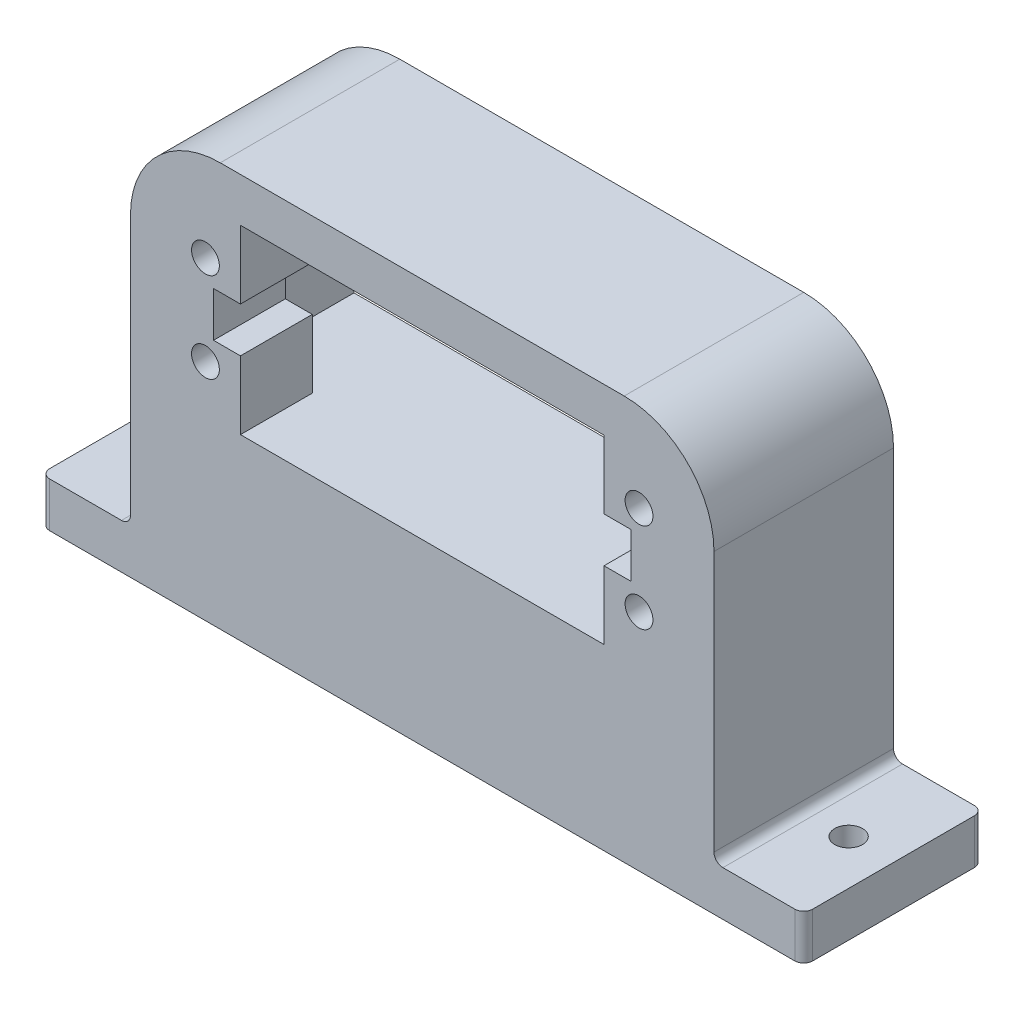
from build123d import *

# Parameters (mm, degrees)
BOSS_EXTRUDE1_DEPTH = 10
SKETCH3_R           = 1.55
CUT_EXTRUDE1_DEPTH  = 12
SKETCH3_3_R         = 1.55
CUT_EXTRUDE3_DEPTH  = 66.048059156
SKETCH5_R           = 1.55
CUT_EXTRUDE4_DEPTH  = 60.213596412
FILLET1_R           = 1


with BuildPart() as part:
    # Sketch1 → Boss-Extrude1 (new, symmetric)
    with BuildSketch(Plane.XY):
        with BuildLine():
            Line((-42.5, 0), (42.5, 0))
            Line((42.5, 0), (42.5, 5))
            Line((42.5, 5), (32.5, 5))
            Line((32.5, 5), (32.5, 35))
            ThreePointArc((32.5, 35), (29.571067812, 42.071067812), (22.5, 45))
            Line((22.5, 45), (-22.5, 45))
            ThreePointArc((-22.5, 45), (-29.571067812, 42.071067812), (-32.5, 35))
            Line((-32.5, 35), (-32.5, 5))
            Line((-32.5, 5), (-42.5, 5))
            Line((-42.5, 5), (-42.5, 0))
        make_face()
    extrude(amount=BOSS_EXTRUDE1_DEPTH, both=True)

    # Sketch3 → Cut-Extrude1 (cut)
    # profile 1 of 2: a face of its own
    with BuildSketch(Plane(origin=(0, 0, -10), x_dir=(-1, 0, 0), z_dir=(0, 0, -1))):
        Polygon((-27.6, 40.1), (-27.6, 19.9), (-20.25, 19.9), (-20.25, 27.5), (-23.25, 27.5), (-23.25, 32.5), (-20.25, 32.5), (-20.25, 40.1), align=None)
        with Locations((-24.15, 25)):
            Circle(SKETCH3_R, mode=Mode.SUBTRACT)
        with Locations((-24.15, 35)):
            Circle(SKETCH3_R, mode=Mode.SUBTRACT)
    # profile 2 of 2: a face of its own
    with BuildSketch(Plane(origin=(0, 0, -10), x_dir=(-1, 0, 0), z_dir=(0, 0, -1))):
        Polygon((20.25, 27.5), (20.25, 19.9), (27.6, 19.9), (27.6, 40.1), (20.25, 40.1), (20.25, 32.5), (23.25, 32.5), (23.25, 27.5), align=None)
        with Locations((24.15, 25)):
            Circle(SKETCH3_R, mode=Mode.SUBTRACT)
        with Locations((24.15, 35)):
            Circle(SKETCH3_R, mode=Mode.SUBTRACT)
    extrude(amount=-CUT_EXTRUDE1_DEPTH, mode=Mode.SUBTRACT)

    # Sketch3_3 → Cut-Extrude3 (cut, through all)
    with BuildSketch(Plane(origin=(0, 0, -10), x_dir=(-1, 0, 0), z_dir=(0, 0, -1))):
        Polygon((-20.25, 27.5), (-20.25, 19.9), (20.25, 19.9), (20.25, 27.5), (23.25, 27.5), (23.25, 32.5), (20.25, 32.5), (20.25, 40.1), (-20.25, 40.1), (-20.25, 32.5), (-23.25, 32.5), (-23.25, 27.5), align=None)
        with Locations((-24.15, 25)):
            Circle(SKETCH3_3_R)
        with Locations((24.15, 25)):
            Circle(SKETCH3_3_R)
        with Locations((-24.15, 35)):
            Circle(SKETCH3_3_R)
        with Locations((24.15, 35)):
            Circle(SKETCH3_3_R)
    extrude(amount=-CUT_EXTRUDE3_DEPTH, mode=Mode.SUBTRACT)

    # Sketch5 → Cut-Extrude4 (cut, through all)
    with BuildSketch(Plane(origin=(0, 5, 0), x_dir=(1, 0, 0), z_dir=(0, 1, 0))):
        with Locations((37.5, 0)):
            Circle(SKETCH5_R)
    cut_extrude4 = extrude(amount=-CUT_EXTRUDE4_DEPTH, mode=Mode.SUBTRACT)

    # Mirror3: Cut-Extrude4 across plane
    add(cut_extrude4.mirror(Plane(origin=(0, 0, 0), x_dir=(0, 0, 1), z_dir=(1, 0, 0))), mode=Mode.SUBTRACT)

    # Fillet1
    fillet1_edges = [part.edges().sort_by_distance(p)[0] for p in [
        (42.5, 2.5, 10),
        (42.5, 2.5, -10),
        (32.5, 5, 0),
        (-42.5, 2.5, 10),
        (-42.5, 2.5, -10),
        (-32.5, 5, 0),
    ]]
    fillet(fillet1_edges, radius=FILLET1_R)


solid = part.part
